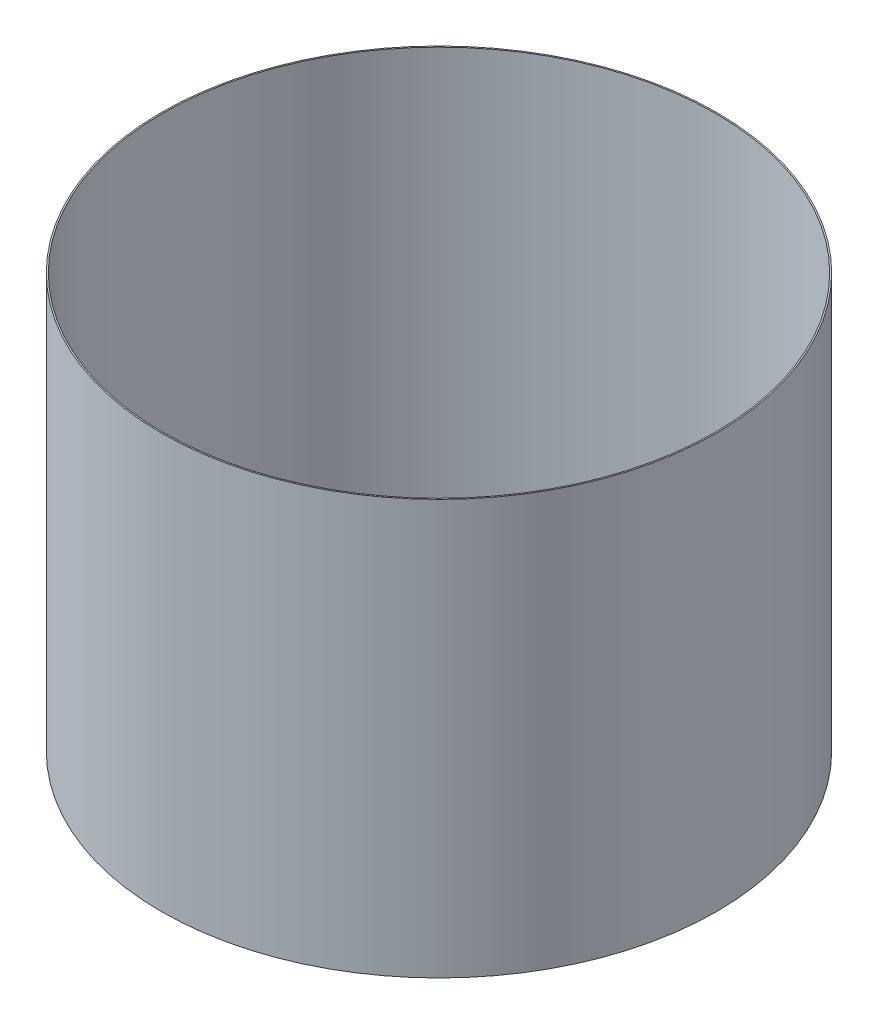
from build123d import *

# Parameters (mm, degrees)
SKETCH1_R      = 2010
SKETCH1_R_2    = 2000
EXTRUDE1_DEPTH = 3000


with BuildPart() as part:
    # Sketch1 → Extrude1 (new body)
    with BuildSketch(Plane(origin=(0, 0, 0), x_dir=(1, 0, 0), z_dir=(0, 1, 0))):
        with Locations(Location((0, 0, 0), (0, 0, 270))):  # turned: the seam where the file's is
            Circle(SKETCH1_R)
        with Locations(Location((0, 0, 0), (0, 0, 270))):  # turned: the seam where the file's is
            Circle(SKETCH1_R_2, mode=Mode.SUBTRACT)
    extrude(amount=EXTRUDE1_DEPTH)


solid = part.part
